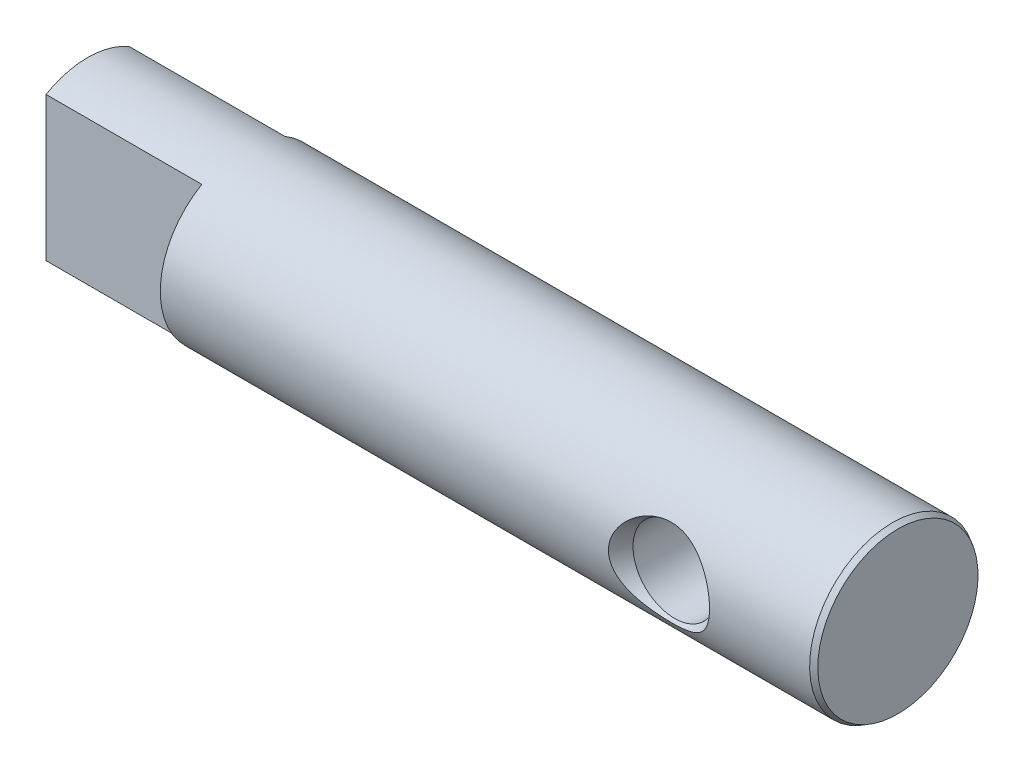
from build123d import *

# Parameters (mm, degrees)
SKIZZE5_OUTSIDE_W               = 34.244
SKIZZE5_OUTSIDE_H               = 34.244
SKIZZE5_OUTSIDE_W_2             = 8
SKIZZE5_OUTSIDE_H_2             = 20
SCHNITT_LINEAR_AUSTRAGEN1_DEPTH = 15
M3_GEWINDEBOHRUNG1_D            = 2.5
M3_GEWINDEBOHRUNG1_DEPTH        = 8.5
M3_GEWINDEBOHRUNG1_TIP          = 0.751075774


with BuildPart() as part:
    # Skizze2 one side → Rotation1 (revolve)
    with BuildSketch(Plane.XY):
        with BuildLine():
            Line((-4, 0), (4, 0))
            ThreePointArc((4, 0), (0, 4), (-4, 0))
        make_face()
        Polygon((-63, 0), (15, 0), (15, 7.711324865), (14.5, 8), (-63, 8), align=None)
    revolve(axis=Axis((15, 0, 0), (-1, 0, 0)))

    # Skizze3 → Schnitt-Rotation1 (revolve, cut)
    with BuildSketch(Plane(origin=(0, 0, 0), x_dir=(1, 0, 0), z_dir=(0, 1, 0))):
        Polygon((-4.866025404, 8), (-4, 6.5), (-4, -6.5), (-4.866025404, -8), (0, -8), (0, 8), align=None)
    revolve(axis=Axis((0, 0, 8), (0, 0, -1)), mode=Mode.SUBTRACT)

    # Skizze5 outside → Schnitt-Linear austragen1 (cut)
    with BuildSketch(Plane.ZY.offset(63)):
        Rectangle(SKIZZE5_OUTSIDE_W, SKIZZE5_OUTSIDE_H)
        Rectangle(SKIZZE5_OUTSIDE_W_2, SKIZZE5_OUTSIDE_H_2, mode=Mode.SUBTRACT)
    extrude(amount=-SCHNITT_LINEAR_AUSTRAGEN1_DEPTH, mode=Mode.SUBTRACT)

    # M3 Gewindebohrung1
    with Locations(Plane.ZY.offset(63)):
        with Locations((0, 0)):
            Hole(M3_GEWINDEBOHRUNG1_D / 2, depth=M3_GEWINDEBOHRUNG1_DEPTH)
            with Locations((0, 0, -(M3_GEWINDEBOHRUNG1_DEPTH + M3_GEWINDEBOHRUNG1_TIP / 2))):  # 118° drill point
                Cone(0, M3_GEWINDEBOHRUNG1_D / 2, M3_GEWINDEBOHRUNG1_TIP, mode=Mode.SUBTRACT)


solid = part.part
